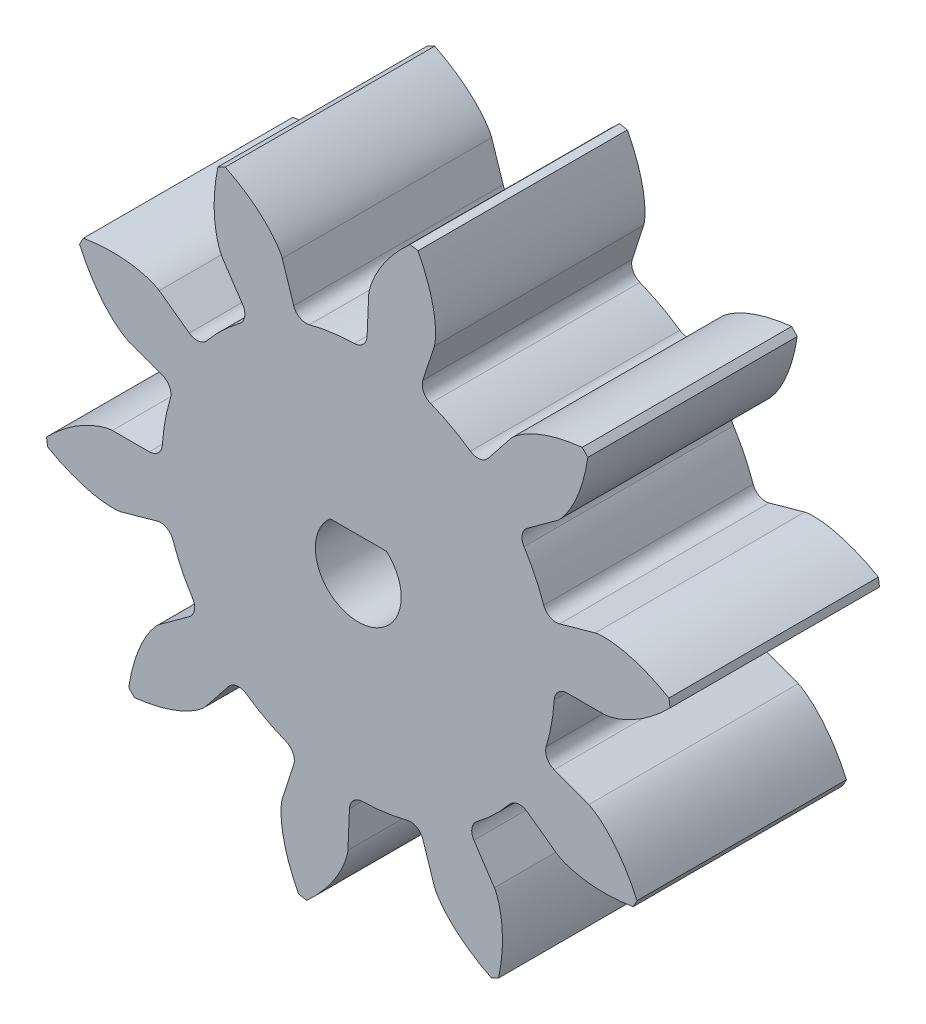
from build123d import *

# Parameters (mm, degrees)
BOSS_EXTRUDE3_DEPTH      = 10
FILLET1_R                = 0.625
CIRPATTERN8_COUNT        = 10
CIRPATTERN8_COPY_1_DEPTH = 10
CIRPATTERN8_COPY_2_DEPTH = 10
CIRPATTERN8_COPY_3_DEPTH = 10
CIRPATTERN8_COPY_4_DEPTH = 10
CIRPATTERN8_COPY_5_DEPTH = 10
CIRPATTERN8_COPY_6_DEPTH = 10
CIRPATTERN8_COPY_7_DEPTH = 10
CIRPATTERN8_COPY_8_DEPTH = 10
CIRPATTERN8_COPY_9_DEPTH = 10
FILLET1_OF_CIRPATTERN8_R = 0.625
SKETCH3_R                = 2.05
CUT_EXTRUDE2_DEPTH       = 11.0000001
BOSS_EXTRUDE4_DEPTH      = 10


with BuildPart() as part:
    # Sketch1 → Boss-Extrude3 (new body)
    with BuildSketch(Plane.XY):
        with BuildLine():
            Line((9.375, 0), (11.74615776, 0))
            add(Edge.make_bspline(
                [(11.74615776, 0), (11.754841732, 0.000183768), (11.779179169, 0.001267888), (11.825088632, 0.005562117), (11.899691958, 0.015746104), (11.994171849, 0.033372696), (12.115394291, 0.0614606), (12.256834487, 0.101322639), (12.410572757, 0.152161687), (12.575722813, 0.214972968), (12.738406771, 0.284201046), (12.898564829, 0.359289485), (13.056063732, 0.439482048), (13.244229139, 0.542891509), (13.466087479, 0.675556037), (13.719390719, 0.842943905), (13.999170912, 1.047118123), (14.275580492, 1.270025494), (14.531397244, 1.493742481), (14.716666587, 1.670363519), (14.8331519, 1.786067897), (14.886668048, 1.84041148)],
                knots=[0, 0, 0, 0, 0, 0.005376748, 0.015083688, 0.02853182, 0.046610139, 0.064854849, 0.092110525, 0.119476175, 0.146842495, 0.174208853, 0.201574955, 0.228941013, 0.256307345, 0.307035032, 0.361767351, 0.41649966, 0.471231936, 0.525964281, 0.573449371, 0.573449371, 0.573449371, 0.573449371, 0.573449371], degree=4))
            ThreePointArc((14.886668048, 1.84041148), (14.874411346, 1.936978864), (14.861528233, 2.033464676))
            Line((14.861528233, 2.033464676), (9.288455145, 1.270915423))
            ThreePointArc((9.288455145, 1.270915423), (9.353338762, 0.636929357), (9.375, 0))
        make_face()
        with BuildLine():
            ThreePointArc((-9.288455145, -1.270915423), (0.636929357, -9.353338762), (9.375, 0))
            ThreePointArc((9.375, 0), (9.353338762, 0.636929357), (9.288455145, 1.270915423))
            Line((9.288455145, 1.270915423), (-9.288455145, -1.270915423))
        make_face()
        with BuildLine():
            Line((-9.288455145, -1.270915423), (9.288455145, 1.270915423))
            ThreePointArc((9.288455145, 1.270915423), (-1.270915423, 9.288455145), (-9.288455145, -1.270915423))
        make_face()
    boss_extrude3 = extrude(amount=BOSS_EXTRUDE3_DEPTH)

    # Mirror2: Boss-Extrude3 across plane
    add(boss_extrude3.mirror(Plane(origin=(0, 0, 10), x_dir=(0, 0, 1), z_dir=(0.135564312, -0.990768549, 0))))

    # Fillet1
    fillet1_edges = [part.edges().sort_by_distance(p)[0] for p in [
        (9.375, 0, 5),
        (9.030418451, 2.518366058, 5),
    ]]
    fillet(fillet1_edges, radius=FILLET1_R)

    # CirPattern8: Boss-Extrude3 ×10 about axis
    cirpattern8_axis = Axis((0, 0, 10), (0, 0, -1))
    for i in range(1, CIRPATTERN8_COUNT):
        add(boss_extrude3.rotate(cirpattern8_axis, i * 360 / CIRPATTERN8_COUNT))

    # CirPattern8 copy 1 sketch → CirPattern8 copy 1 (add)
    with BuildSketch(Plane(origin=(0, 0, 0), x_dir=(0.937175512, -0.348858224, 0), z_dir=(0, 0, 1))):
        with BuildLine():
            Line((9.375, 0), (11.74615776, 0))
            add(Edge.make_bspline(
                [(11.74615776, 0), (11.754841732, -0.000183768), (11.779179169, -0.001267888), (11.825088632, -0.005562117), (11.899691958, -0.015746104), (11.994171849, -0.033372696), (12.115394291, -0.0614606), (12.256834487, -0.101322639), (12.410572757, -0.152161687), (12.575722813, -0.214972968), (12.738406771, -0.284201046), (12.898564829, -0.359289485), (13.056063732, -0.439482048), (13.244229139, -0.542891509), (13.466087479, -0.675556037), (13.719390719, -0.842943905), (13.999170912, -1.047118123), (14.275580492, -1.270025494), (14.531397244, -1.493742481), (14.716666587, -1.670363519), (14.8331519, -1.786067897), (14.886668048, -1.84041148)],
                knots=[0, 0, 0, 0, 0, 0.005376748, 0.015083688, 0.02853182, 0.046610139, 0.064854849, 0.092110525, 0.119476175, 0.146842495, 0.174208853, 0.201574955, 0.228941013, 0.256307345, 0.307035032, 0.361767351, 0.41649966, 0.471231936, 0.525964281, 0.573449371, 0.573449371, 0.573449371, 0.573449371, 0.573449371], degree=4))
            ThreePointArc((14.886668048, -1.84041148), (14.874411346, -1.936978864), (14.861528233, -2.033464676))
            Line((14.861528233, -2.033464676), (9.288455145, -1.270915423))
            ThreePointArc((9.288455145, -1.270915423), (9.353338762, -0.636929357), (9.375, 0))
        make_face()
        with BuildLine():
            ThreePointArc((-9.288455145, 1.270915423), (0.636929357, 9.353338762), (9.375, 0))
            ThreePointArc((9.375, 0), (9.353338762, -0.636929357), (9.288455145, -1.270915423))
            Line((9.288455145, -1.270915423), (-9.288455145, 1.270915423))
        make_face()
        with BuildLine():
            Line((-9.288455145, 1.270915423), (9.288455145, -1.270915423))
            ThreePointArc((9.288455145, -1.270915423), (-1.270915423, -9.288455145), (-9.288455145, 1.270915423))
        make_face()
    extrude(amount=CIRPATTERN8_COPY_1_DEPTH)

    # CirPattern8 copy 2 sketch → CirPattern8 copy 2 (add)
    with BuildSketch(Plane(origin=(0, 0, 0), x_dir=(0.553137197, -0.833090176, 0), z_dir=(0, 0, 1))):
        with BuildLine():
            Line((9.375, 0), (11.74615776, 0))
            add(Edge.make_bspline(
                [(11.74615776, 0), (11.754841732, -0.000183768), (11.779179169, -0.001267888), (11.825088632, -0.005562117), (11.899691958, -0.015746104), (11.994171849, -0.033372696), (12.115394291, -0.0614606), (12.256834487, -0.101322639), (12.410572757, -0.152161687), (12.575722813, -0.214972968), (12.738406771, -0.284201046), (12.898564829, -0.359289485), (13.056063732, -0.439482048), (13.244229139, -0.542891509), (13.466087479, -0.675556037), (13.719390719, -0.842943905), (13.999170912, -1.047118123), (14.275580492, -1.270025494), (14.531397244, -1.493742481), (14.716666587, -1.670363519), (14.8331519, -1.786067897), (14.886668048, -1.84041148)],
                knots=[0, 0, 0, 0, 0, 0.005376748, 0.015083688, 0.02853182, 0.046610139, 0.064854849, 0.092110525, 0.119476175, 0.146842495, 0.174208853, 0.201574955, 0.228941013, 0.256307345, 0.307035032, 0.361767351, 0.41649966, 0.471231936, 0.525964281, 0.573449371, 0.573449371, 0.573449371, 0.573449371, 0.573449371], degree=4))
            ThreePointArc((14.886668048, -1.84041148), (14.874411346, -1.936978864), (14.861528233, -2.033464676))
            Line((14.861528233, -2.033464676), (9.288455145, -1.270915423))
            ThreePointArc((9.288455145, -1.270915423), (9.353338762, -0.636929357), (9.375, 0))
        make_face()
        with BuildLine():
            ThreePointArc((-9.288455145, 1.270915423), (0.636929357, 9.353338762), (9.375, 0))
            ThreePointArc((9.375, 0), (9.353338762, -0.636929357), (9.288455145, -1.270915423))
            Line((9.288455145, -1.270915423), (-9.288455145, 1.270915423))
        make_face()
        with BuildLine():
            Line((-9.288455145, 1.270915423), (9.288455145, -1.270915423))
            ThreePointArc((9.288455145, -1.270915423), (-1.270915423, -9.288455145), (-9.288455145, 1.270915423))
        make_face()
    extrude(amount=CIRPATTERN8_COPY_2_DEPTH)

    # CirPattern8 copy 3 sketch → CirPattern8 copy 3 (add)
    with BuildSketch(Plane(origin=(0, 0, 0), x_dir=(-0.042180727, -0.999109997, 0), z_dir=(0, 0, 1))):
        with BuildLine():
            Line((9.375, 0), (11.74615776, 0))
            add(Edge.make_bspline(
                [(11.74615776, 0), (11.754841732, -0.000183768), (11.779179169, -0.001267888), (11.825088632, -0.005562117), (11.899691958, -0.015746104), (11.994171849, -0.033372696), (12.115394291, -0.0614606), (12.256834487, -0.101322639), (12.410572757, -0.152161687), (12.575722813, -0.214972968), (12.738406771, -0.284201046), (12.898564829, -0.359289485), (13.056063732, -0.439482048), (13.244229139, -0.542891509), (13.466087479, -0.675556037), (13.719390719, -0.842943905), (13.999170912, -1.047118123), (14.275580492, -1.270025494), (14.531397244, -1.493742481), (14.716666587, -1.670363519), (14.8331519, -1.786067897), (14.886668048, -1.84041148)],
                knots=[0, 0, 0, 0, 0, 0.005376748, 0.015083688, 0.02853182, 0.046610139, 0.064854849, 0.092110525, 0.119476175, 0.146842495, 0.174208853, 0.201574955, 0.228941013, 0.256307345, 0.307035032, 0.361767351, 0.41649966, 0.471231936, 0.525964281, 0.573449371, 0.573449371, 0.573449371, 0.573449371, 0.573449371], degree=4))
            ThreePointArc((14.886668048, -1.84041148), (14.874411346, -1.936978864), (14.861528233, -2.033464676))
            Line((14.861528233, -2.033464676), (9.288455145, -1.270915423))
            ThreePointArc((9.288455145, -1.270915423), (9.353338762, -0.636929357), (9.375, 0))
        make_face()
        with BuildLine():
            ThreePointArc((-9.288455145, 1.270915423), (0.636929357, 9.353338762), (9.375, 0))
            ThreePointArc((9.375, 0), (9.353338762, -0.636929357), (9.288455145, -1.270915423))
            Line((9.288455145, -1.270915423), (-9.288455145, 1.270915423))
        make_face()
        with BuildLine():
            Line((-9.288455145, 1.270915423), (9.288455145, -1.270915423))
            ThreePointArc((9.288455145, -1.270915423), (-1.270915423, -9.288455145), (-9.288455145, 1.270915423))
        make_face()
    extrude(amount=CIRPATTERN8_COPY_3_DEPTH)

    # CirPattern8 copy 4 sketch → CirPattern8 copy 4 (add)
    with BuildSketch(Plane(origin=(0, 0, 0), x_dir=(-0.621387047, -0.783503757, 0), z_dir=(0, 0, 1))):
        with BuildLine():
            Line((9.375, 0), (11.74615776, 0))
            add(Edge.make_bspline(
                [(11.74615776, 0), (11.754841732, -0.000183768), (11.779179169, -0.001267888), (11.825088632, -0.005562117), (11.899691958, -0.015746104), (11.994171849, -0.033372696), (12.115394291, -0.0614606), (12.256834487, -0.101322639), (12.410572757, -0.152161687), (12.575722813, -0.214972968), (12.738406771, -0.284201046), (12.898564829, -0.359289485), (13.056063732, -0.439482048), (13.244229139, -0.542891509), (13.466087479, -0.675556037), (13.719390719, -0.842943905), (13.999170912, -1.047118123), (14.275580492, -1.270025494), (14.531397244, -1.493742481), (14.716666587, -1.670363519), (14.8331519, -1.786067897), (14.886668048, -1.84041148)],
                knots=[0, 0, 0, 0, 0, 0.005376748, 0.015083688, 0.02853182, 0.046610139, 0.064854849, 0.092110525, 0.119476175, 0.146842495, 0.174208853, 0.201574955, 0.228941013, 0.256307345, 0.307035032, 0.361767351, 0.41649966, 0.471231936, 0.525964281, 0.573449371, 0.573449371, 0.573449371, 0.573449371, 0.573449371], degree=4))
            ThreePointArc((14.886668048, -1.84041148), (14.874411346, -1.936978864), (14.861528233, -2.033464676))
            Line((14.861528233, -2.033464676), (9.288455145, -1.270915423))
            ThreePointArc((9.288455145, -1.270915423), (9.353338762, -0.636929357), (9.375, 0))
        make_face()
        with BuildLine():
            ThreePointArc((-9.288455145, 1.270915423), (0.636929357, 9.353338762), (9.375, 0))
            ThreePointArc((9.375, 0), (9.353338762, -0.636929357), (9.288455145, -1.270915423))
            Line((9.288455145, -1.270915423), (-9.288455145, 1.270915423))
        make_face()
        with BuildLine():
            Line((-9.288455145, 1.270915423), (9.288455145, -1.270915423))
            ThreePointArc((9.288455145, -1.270915423), (-1.270915423, -9.288455145), (-9.288455145, 1.270915423))
        make_face()
    extrude(amount=CIRPATTERN8_COPY_4_DEPTH)

    # CirPattern8 copy 5 sketch → CirPattern8 copy 5 (add)
    with BuildSketch(Plane(origin=(0, 0, 0), x_dir=(-0.963244635, -0.268625713, 0), z_dir=(0, 0, 1))):
        with BuildLine():
            Line((9.375, 0), (11.74615776, 0))
            add(Edge.make_bspline(
                [(11.74615776, 0), (11.754841732, -0.000183768), (11.779179169, -0.001267888), (11.825088632, -0.005562117), (11.899691958, -0.015746104), (11.994171849, -0.033372696), (12.115394291, -0.0614606), (12.256834487, -0.101322639), (12.410572757, -0.152161687), (12.575722813, -0.214972968), (12.738406771, -0.284201046), (12.898564829, -0.359289485), (13.056063732, -0.439482048), (13.244229139, -0.542891509), (13.466087479, -0.675556037), (13.719390719, -0.842943905), (13.999170912, -1.047118123), (14.275580492, -1.270025494), (14.531397244, -1.493742481), (14.716666587, -1.670363519), (14.8331519, -1.786067897), (14.886668048, -1.84041148)],
                knots=[0, 0, 0, 0, 0, 0.005376748, 0.015083688, 0.02853182, 0.046610139, 0.064854849, 0.092110525, 0.119476175, 0.146842495, 0.174208853, 0.201574955, 0.228941013, 0.256307345, 0.307035032, 0.361767351, 0.41649966, 0.471231936, 0.525964281, 0.573449371, 0.573449371, 0.573449371, 0.573449371, 0.573449371], degree=4))
            ThreePointArc((14.886668048, -1.84041148), (14.874411346, -1.936978864), (14.861528233, -2.033464676))
            Line((14.861528233, -2.033464676), (9.288455145, -1.270915423))
            ThreePointArc((9.288455145, -1.270915423), (9.353338762, -0.636929357), (9.375, 0))
        make_face()
        with BuildLine():
            ThreePointArc((-9.288455145, 1.270915423), (0.636929357, 9.353338762), (9.375, 0))
            ThreePointArc((9.375, 0), (9.353338762, -0.636929357), (9.288455145, -1.270915423))
            Line((9.288455145, -1.270915423), (-9.288455145, 1.270915423))
        make_face()
        with BuildLine():
            Line((-9.288455145, 1.270915423), (9.288455145, -1.270915423))
            ThreePointArc((9.288455145, -1.270915423), (-1.270915423, -9.288455145), (-9.288455145, 1.270915423))
        make_face()
    extrude(amount=CIRPATTERN8_COPY_5_DEPTH)

    # CirPattern8 copy 6 sketch → CirPattern8 copy 6 (add)
    with BuildSketch(Plane(origin=(0, 0, 0), x_dir=(-0.937175512, 0.348858224, 0), z_dir=(0, 0, 1))):
        with BuildLine():
            Line((9.375, 0), (11.74615776, 0))
            add(Edge.make_bspline(
                [(11.74615776, 0), (11.754841732, -0.000183768), (11.779179169, -0.001267888), (11.825088632, -0.005562117), (11.899691958, -0.015746104), (11.994171849, -0.033372696), (12.115394291, -0.0614606), (12.256834487, -0.101322639), (12.410572757, -0.152161687), (12.575722813, -0.214972968), (12.738406771, -0.284201046), (12.898564829, -0.359289485), (13.056063732, -0.439482048), (13.244229139, -0.542891509), (13.466087479, -0.675556037), (13.719390719, -0.842943905), (13.999170912, -1.047118123), (14.275580492, -1.270025494), (14.531397244, -1.493742481), (14.716666587, -1.670363519), (14.8331519, -1.786067897), (14.886668048, -1.84041148)],
                knots=[0, 0, 0, 0, 0, 0.005376748, 0.015083688, 0.02853182, 0.046610139, 0.064854849, 0.092110525, 0.119476175, 0.146842495, 0.174208853, 0.201574955, 0.228941013, 0.256307345, 0.307035032, 0.361767351, 0.41649966, 0.471231936, 0.525964281, 0.573449371, 0.573449371, 0.573449371, 0.573449371, 0.573449371], degree=4))
            ThreePointArc((14.886668048, -1.84041148), (14.874411346, -1.936978864), (14.861528233, -2.033464676))
            Line((14.861528233, -2.033464676), (9.288455145, -1.270915423))
            ThreePointArc((9.288455145, -1.270915423), (9.353338762, -0.636929357), (9.375, 0))
        make_face()
        with BuildLine():
            ThreePointArc((-9.288455145, 1.270915423), (0.636929357, 9.353338762), (9.375, 0))
            ThreePointArc((9.375, 0), (9.353338762, -0.636929357), (9.288455145, -1.270915423))
            Line((9.288455145, -1.270915423), (-9.288455145, 1.270915423))
        make_face()
        with BuildLine():
            Line((-9.288455145, 1.270915423), (9.288455145, -1.270915423))
            ThreePointArc((9.288455145, -1.270915423), (-1.270915423, -9.288455145), (-9.288455145, 1.270915423))
        make_face()
    extrude(amount=CIRPATTERN8_COPY_6_DEPTH)

    # CirPattern8 copy 7 sketch → CirPattern8 copy 7 (add)
    with BuildSketch(Plane(origin=(0, 0, 0), x_dir=(-0.553137197, 0.833090176, 0), z_dir=(0, 0, 1))):
        with BuildLine():
            Line((9.375, 0), (11.74615776, 0))
            add(Edge.make_bspline(
                [(11.74615776, 0), (11.754841732, -0.000183768), (11.779179169, -0.001267888), (11.825088632, -0.005562117), (11.899691958, -0.015746104), (11.994171849, -0.033372696), (12.115394291, -0.0614606), (12.256834487, -0.101322639), (12.410572757, -0.152161687), (12.575722813, -0.214972968), (12.738406771, -0.284201046), (12.898564829, -0.359289485), (13.056063732, -0.439482048), (13.244229139, -0.542891509), (13.466087479, -0.675556037), (13.719390719, -0.842943905), (13.999170912, -1.047118123), (14.275580492, -1.270025494), (14.531397244, -1.493742481), (14.716666587, -1.670363519), (14.8331519, -1.786067897), (14.886668048, -1.84041148)],
                knots=[0, 0, 0, 0, 0, 0.005376748, 0.015083688, 0.02853182, 0.046610139, 0.064854849, 0.092110525, 0.119476175, 0.146842495, 0.174208853, 0.201574955, 0.228941013, 0.256307345, 0.307035032, 0.361767351, 0.41649966, 0.471231936, 0.525964281, 0.573449371, 0.573449371, 0.573449371, 0.573449371, 0.573449371], degree=4))
            ThreePointArc((14.886668048, -1.84041148), (14.874411346, -1.936978864), (14.861528233, -2.033464676))
            Line((14.861528233, -2.033464676), (9.288455145, -1.270915423))
            ThreePointArc((9.288455145, -1.270915423), (9.353338762, -0.636929357), (9.375, 0))
        make_face()
        with BuildLine():
            ThreePointArc((-9.288455145, 1.270915423), (0.636929357, 9.353338762), (9.375, 0))
            ThreePointArc((9.375, 0), (9.353338762, -0.636929357), (9.288455145, -1.270915423))
            Line((9.288455145, -1.270915423), (-9.288455145, 1.270915423))
        make_face()
        with BuildLine():
            Line((-9.288455145, 1.270915423), (9.288455145, -1.270915423))
            ThreePointArc((9.288455145, -1.270915423), (-1.270915423, -9.288455145), (-9.288455145, 1.270915423))
        make_face()
    extrude(amount=CIRPATTERN8_COPY_7_DEPTH)

    # CirPattern8 copy 8 sketch → CirPattern8 copy 8 (add)
    with BuildSketch(Plane(origin=(0, 0, 0), x_dir=(0.042180727, 0.999109997, 0), z_dir=(0, 0, 1))):
        with BuildLine():
            Line((9.375, 0), (11.74615776, 0))
            add(Edge.make_bspline(
                [(11.74615776, 0), (11.754841732, -0.000183768), (11.779179169, -0.001267888), (11.825088632, -0.005562117), (11.899691958, -0.015746104), (11.994171849, -0.033372696), (12.115394291, -0.0614606), (12.256834487, -0.101322639), (12.410572757, -0.152161687), (12.575722813, -0.214972968), (12.738406771, -0.284201046), (12.898564829, -0.359289485), (13.056063732, -0.439482048), (13.244229139, -0.542891509), (13.466087479, -0.675556037), (13.719390719, -0.842943905), (13.999170912, -1.047118123), (14.275580492, -1.270025494), (14.531397244, -1.493742481), (14.716666587, -1.670363519), (14.8331519, -1.786067897), (14.886668048, -1.84041148)],
                knots=[0, 0, 0, 0, 0, 0.005376748, 0.015083688, 0.02853182, 0.046610139, 0.064854849, 0.092110525, 0.119476175, 0.146842495, 0.174208853, 0.201574955, 0.228941013, 0.256307345, 0.307035032, 0.361767351, 0.41649966, 0.471231936, 0.525964281, 0.573449371, 0.573449371, 0.573449371, 0.573449371, 0.573449371], degree=4))
            ThreePointArc((14.886668048, -1.84041148), (14.874411346, -1.936978864), (14.861528233, -2.033464676))
            Line((14.861528233, -2.033464676), (9.288455145, -1.270915423))
            ThreePointArc((9.288455145, -1.270915423), (9.353338762, -0.636929357), (9.375, 0))
        make_face()
        with BuildLine():
            ThreePointArc((-9.288455145, 1.270915423), (0.636929357, 9.353338762), (9.375, 0))
            ThreePointArc((9.375, 0), (9.353338762, -0.636929357), (9.288455145, -1.270915423))
            Line((9.288455145, -1.270915423), (-9.288455145, 1.270915423))
        make_face()
        with BuildLine():
            Line((-9.288455145, 1.270915423), (9.288455145, -1.270915423))
            ThreePointArc((9.288455145, -1.270915423), (-1.270915423, -9.288455145), (-9.288455145, 1.270915423))
        make_face()
    extrude(amount=CIRPATTERN8_COPY_8_DEPTH)

    # CirPattern8 copy 9 sketch → CirPattern8 copy 9 (add)
    with BuildSketch(Plane(origin=(0, 0, 0), x_dir=(0.621387047, 0.783503757, 0), z_dir=(0, 0, 1))):
        with BuildLine():
            Line((9.375, 0), (11.74615776, 0))
            add(Edge.make_bspline(
                [(11.74615776, 0), (11.754841732, -0.000183768), (11.779179169, -0.001267888), (11.825088632, -0.005562117), (11.899691958, -0.015746104), (11.994171849, -0.033372696), (12.115394291, -0.0614606), (12.256834487, -0.101322639), (12.410572757, -0.152161687), (12.575722813, -0.214972968), (12.738406771, -0.284201046), (12.898564829, -0.359289485), (13.056063732, -0.439482048), (13.244229139, -0.542891509), (13.466087479, -0.675556037), (13.719390719, -0.842943905), (13.999170912, -1.047118123), (14.275580492, -1.270025494), (14.531397244, -1.493742481), (14.716666587, -1.670363519), (14.8331519, -1.786067897), (14.886668048, -1.84041148)],
                knots=[0, 0, 0, 0, 0, 0.005376748, 0.015083688, 0.02853182, 0.046610139, 0.064854849, 0.092110525, 0.119476175, 0.146842495, 0.174208853, 0.201574955, 0.228941013, 0.256307345, 0.307035032, 0.361767351, 0.41649966, 0.471231936, 0.525964281, 0.573449371, 0.573449371, 0.573449371, 0.573449371, 0.573449371], degree=4))
            ThreePointArc((14.886668048, -1.84041148), (14.874411346, -1.936978864), (14.861528233, -2.033464676))
            Line((14.861528233, -2.033464676), (9.288455145, -1.270915423))
            ThreePointArc((9.288455145, -1.270915423), (9.353338762, -0.636929357), (9.375, 0))
        make_face()
        with BuildLine():
            ThreePointArc((-9.288455145, 1.270915423), (0.636929357, 9.353338762), (9.375, 0))
            ThreePointArc((9.375, 0), (9.353338762, -0.636929357), (9.288455145, -1.270915423))
            Line((9.288455145, -1.270915423), (-9.288455145, 1.270915423))
        make_face()
        with BuildLine():
            Line((-9.288455145, 1.270915423), (9.288455145, -1.270915423))
            ThreePointArc((9.288455145, -1.270915423), (-1.270915423, -9.288455145), (-9.288455145, 1.270915423))
        make_face()
    extrude(amount=CIRPATTERN8_COPY_9_DEPTH)

    # Fillet1 of CirPattern8
    fillet1_of_cirpattern8_edges = [part.edges().sort_by_distance(p)[0] for p in [
        (7.584534322, -5.51048674, 5),
        (8.786020422, -3.270545849, 5),
        (2.897034322, -8.91615484, 5),
        (5.185661217, -7.810220403, 5),
        (-2.897034322, -8.91615484, 5),
        (-0.395444318, -9.366656223, 5),
        (-7.584534322, -5.51048674, 5),
        (-5.825503564, -7.345347726, 5),
        (-9.375, 0, 5),
        (-9.030418451, -2.518366058, 5),
        (-7.584534322, 5.51048674, 5),
        (-8.786020422, 3.270545849, 5),
        (-2.897034322, 8.91615484, 5),
        (-5.185661217, 7.810220403, 5),
        (2.897034322, 8.91615484, 5),
        (0.395444318, 9.366656223, 5),
        (7.584534322, 5.51048674, 5),
        (5.825503564, 7.345347726, 5),
    ]]
    fillet(fillet1_of_cirpattern8_edges, radius=FILLET1_OF_CIRPATTERN8_R)

    # Sketch3 → Cut-Extrude2 (cut, through all)
    with BuildSketch(Plane.XY.offset(10)):
        Circle(SKETCH3_R)
    extrude(amount=-CUT_EXTRUDE2_DEPTH, mode=Mode.SUBTRACT)

    # Sketch4 → Boss-Extrude4 (add)
    with BuildSketch(Plane(origin=(0, 0, 0), x_dir=(-1, 0, 0), z_dir=(0, 0, -1))):
        with BuildLine():
            ThreePointArc((1.341640786, 1.55), (0, 2.05), (-1.341640786, 1.55))
            Line((-1.341640786, 1.55), (1.341640786, 1.55))
        make_face()
    extrude(amount=-BOSS_EXTRUDE4_DEPTH)


solid = part.part
